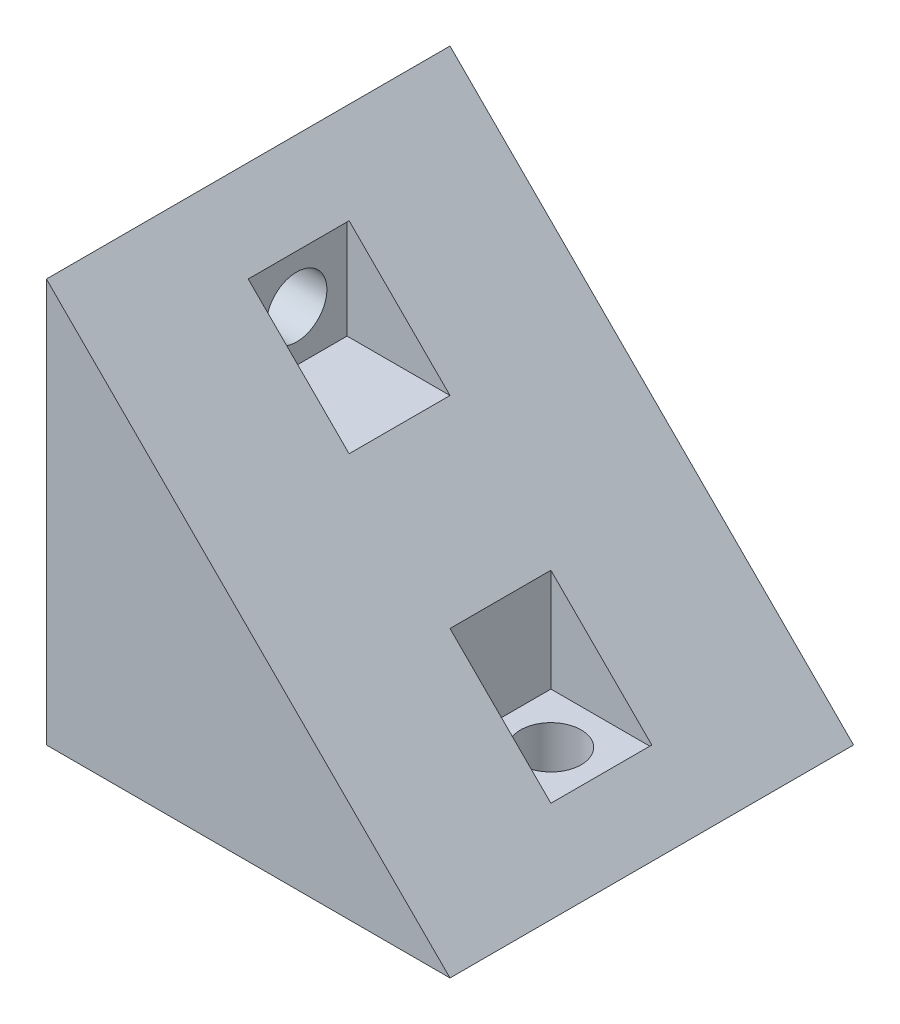
from build123d import *

# Parameters (mm, degrees)
BOSS_EXTRU_1_DEPTH      = 40
ENL_V_MAT_EXTRU_1_REACH = 42
ESQUISSE3_R             = 3
ENL_V_MAT_EXTRU_2_REACH = 42
ESQUISSE4_R             = 3
ENL_V_MAT_EXTRU_4_REACH = 37.2
ESQUISSE9_W             = 10
ESQUISSE9_H             = 10
ENL_V_MAT_EXTRU_5_REACH = 37.2
ESQUISSE10_W            = 10
ESQUISSE10_H            = 10


with BuildPart() as part:
    # Esquisse2 → Boss.-Extru.1 (new body)
    with BuildSketch(Plane.XY):
        Polygon((0, 0), (0, 40), (40, 0), align=None)
    extrude(amount=BOSS_EXTRU_1_DEPTH)

    # Esquisse3 → Enlèv. mat.-Extru.1 (cut, up to next)
    with BuildSketch(Plane.XZ, mode=Mode.PRIVATE) as enl_v_mat_extru_1_sk1:
        with Locations((30, 20)):
            Circle(ESQUISSE3_R)
    enl_v_mat_extru_1_tool1 = extrude(enl_v_mat_extru_1_sk1.sketch, amount=-ENL_V_MAT_EXTRU_1_REACH, mode=Mode.PRIVATE) & part.part
    add(enl_v_mat_extru_1_tool1.solids().sort_by_distance((30, 0, 20))[0], mode=Mode.SUBTRACT)

    # Esquisse4 → Enlèv. mat.-Extru.2 (cut, up to next)
    with BuildSketch(Plane.ZY, mode=Mode.PRIVATE) as enl_v_mat_extru_2_sk1:
        with Locations((20, 30)):
            Circle(ESQUISSE4_R)
    enl_v_mat_extru_2_tool1 = extrude(enl_v_mat_extru_2_sk1.sketch, amount=-ENL_V_MAT_EXTRU_2_REACH, mode=Mode.PRIVATE) & part.part
    add(enl_v_mat_extru_2_tool1.solids().sort_by_distance((0, 30, 20))[0], mode=Mode.SUBTRACT)

    # Esquisse9 → Enlèv. mat.-Extru.4 (cut, up to next)
    with BuildSketch(Plane.ZY.offset(-4.8), mode=Mode.PRIVATE) as enl_v_mat_extru_4_sk1:
        with Locations((20, 30)):
            Rectangle(ESQUISSE9_W, ESQUISSE9_H)
    enl_v_mat_extru_4_tool1 = extrude(enl_v_mat_extru_4_sk1.sketch, amount=-ENL_V_MAT_EXTRU_4_REACH, mode=Mode.PRIVATE) & part.part
    add(enl_v_mat_extru_4_tool1.solids().sort_by_distance((4.8, 30, 20))[0], mode=Mode.SUBTRACT)

    # Esquisse10 → Enlèv. mat.-Extru.5 (cut, up to next)
    with BuildSketch(Plane(origin=(0, 4.8, 0), x_dir=(0, 0, 1), z_dir=(0, -1, 0)), mode=Mode.PRIVATE) as enl_v_mat_extru_5_sk1:
        with Locations((20, -30)):
            Rectangle(ESQUISSE10_W, ESQUISSE10_H)
    enl_v_mat_extru_5_tool1 = extrude(enl_v_mat_extru_5_sk1.sketch, amount=-ENL_V_MAT_EXTRU_5_REACH, mode=Mode.PRIVATE) & part.part
    add(enl_v_mat_extru_5_tool1.solids().sort_by_distance((30, 4.8, 20))[0], mode=Mode.SUBTRACT)


solid = part.part
